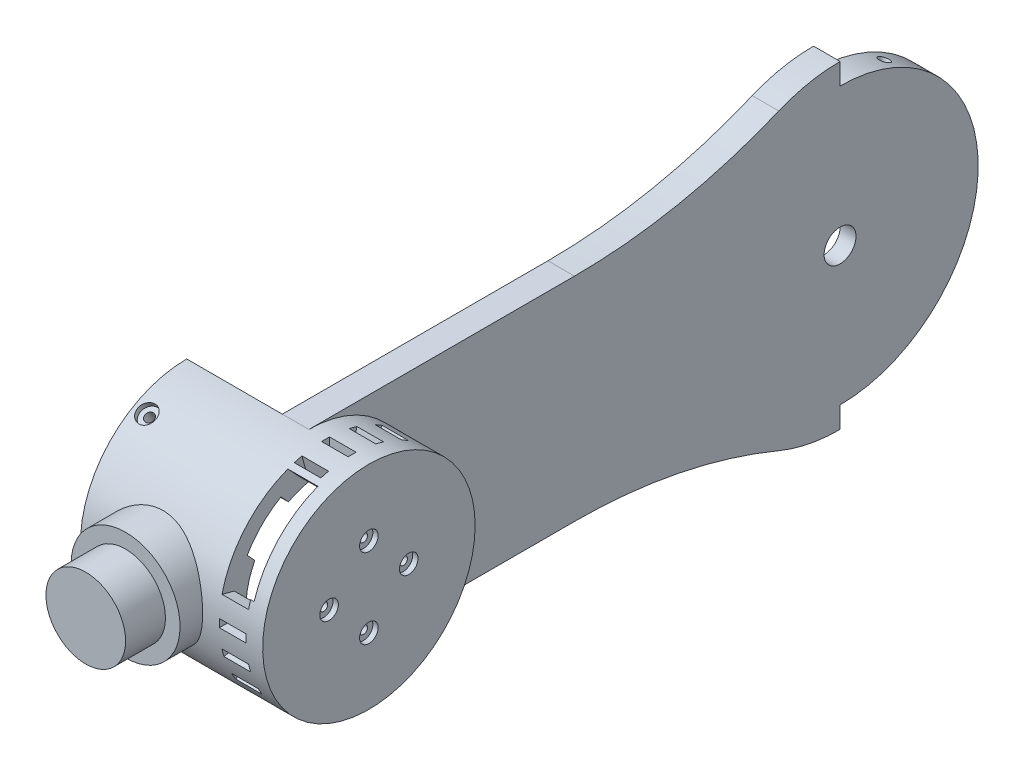
from build123d import *
from build123d.topology import SkipClean

# Parameters (mm, degrees)
SKETCH1_R                                            = 60
SKETCH1_R_2                                          = 45
SKETCH1_R_3                                          = 40
BOSS_EXTRUDE3_DEPTH                                  = 10
CUT_EXTRUDE1_DEPTH                                   = 248.588368063
CUT_EXTRUDE1_DEPTH_BACK                              = 248.588368063
SKETCH5_R                                            = 30
CUT_EXTRUDE2_DEPTH                                   = 248.588368063
CUT_EXTRUDE2_DEPTH_BACK                              = 248.588368063
SKETCH6_R                                            = 18.5
CUT_EXTRUDE3_DEPTH                                   = 4
SKETCH7_R                                            = 40
SKETCH7_R_2                                          = 30
BOSS_EXTRUDE4_DEPTH                                  = 17.6
SKETCH8_R                                            = 40
BOSS_EXTRUDE5_DEPTH                                  = 5
SKETCH9_R                                            = 1.5
CUT_EXTRUDE4_DEPTH                                   = 249.921192348
CUT_EXTRUDE4_DEPTH_BACK                              = 249.921192348
BOSS_EXTRUDE6_DEPTH                                  = 31
BOSS_EXTRUDE8_REACH                                  = 301.878
BOSS_EXTRUDE8_END_RADIUS                             = 40
SKETCH13_R                                           = 20.5
BOSS_EXTRUDE8_DIRECTION_2_DEPTH                      = 8.5
SKETCH16_R                                           = 15
BOSS_EXTRUDE9_DEPTH                                  = 15
SKETCH17_R                                           = 3.5
CUT_EXTRUDE5_DEPTH                                   = 2
BOSS_EXTRUDE11_DEPTH                                 = 5
CBORE_FOR_M3_HEXAGON_HEAD_BOLTS_FULL_THR_D           = 3.4
CBORE_FOR_M3_HEXAGON_HEAD_BOLTS_FULL_THR_CBORE_D     = 7
CBORE_FOR_M3_HEXAGON_HEAD_BOLTS_FULL_THR_CBORE_DEPTH = 2
CBORE_FOR_M3_HEXAGON_HEAD_BOLTS_FULL_2_D             = 3.4
CBORE_FOR_M3_HEXAGON_HEAD_BOLTS_FULL_2_CBORE_D       = 7
CBORE_FOR_M3_HEXAGON_HEAD_BOLTS_FULL_2_CBORE_DEPTH   = 2
SKETCH21_R                                           = 2.05
CUT_EXTRUDE6_DEPTH                                   = 13
SKETCH22_R                                           = 2.05
CUT_EXTRUDE7_DEPTH                                   = 13
F_4_0MM_DOWEL_HOLE1_D                                = 4.1
F_4_0MM_DOWEL_HOLE1_DEPTH                            = 7
F_4_0MM_DOWEL_HOLE1_TIP                              = 1.231764269
SKETCH24_R                                           = 6
CUT_EXTRUDE8_DEPTH                                   = 2.5
CUT_EXTRUDE9_REACH                                   = 310.539
CUT_EXTRUDE9_END_RADIUS                              = 30
SKETCH25_W                                           = 10
SKETCH25_H                                           = 3
CIRPATTERN1_COUNT                                    = 24
CUT_EXTRUDE10_REACH                                  = 301.691
CUT_EXTRUDE10_END_RADIUS                             = 30
SKETCH26_W                                           = 11.3
SKETCH26_H                                           = 35
CUT_EXTRUDE11_REACH                                  = 250.012
CUT_EXTRUDE11_END_RADIUS                             = 30
SKETCH27_W                                           = 32.246130699
SKETCH27_H                                           = 17.935567755
CUT_EXTRUDE11_DIRECTION_2_REACH                      = 250.012
CUT_EXTRUDE11_DIRECTION_2_END_RADIUS                 = 34
CUT_EXTRUDE12_REACH                                  = 275.189
SKETCH28_R                                           = 6


with BuildPart() as part:
    # Sketch1 → Boss-Extrude3 (new body)
    with BuildSketch(Plane(origin=(0, 0, 0), x_dir=(0, 0, -1), z_dir=(1, 0, 0))):
        Circle(SKETCH1_R)
        Circle(SKETCH1_R_2, mode=Mode.SUBTRACT)
        with BuildLine():
            ThreePointArc((-23.076923077, 55.384615385), (-60.776772972, 43.883864862), (-100, 40))
            Line((-100, 40), (-200, 40))
            ThreePointArc((-200, 40), (-171.715728753, 28.284271247), (-160, 0))
            ThreePointArc((-160, 0), (-171.715728753, -28.284271247), (-200, -40))
            Line((-200, -40), (-100, -40))
            ThreePointArc((-100, -40), (-60.776772972, -43.883864862), (-23.076923077, -55.384615385))
            ThreePointArc((-23.076923077, -55.384615385), (-60, 0), (-23.076923077, 55.384615385))
        make_face()
        with Locations((-200, 0)):
            Circle(SKETCH1_R_3)
        Circle(SKETCH1_R_2)
    extrude(amount=BOSS_EXTRUDE3_DEPTH)

    # Sketch4 → Cut-Extrude1 (cut, two sides)
    with BuildSketch(Plane(origin=(10, 0, 0), x_dir=(0, 0, -1), z_dir=(1, 0, 0))) as cut_extrude1_sk:
        with BuildLine():
            Line((0, 60), (0, 52))
            ThreePointArc((0, 52), (36.769552622, 36.769552622), (52, 0))
            ThreePointArc((52, 0), (36.769552622, -36.769552622), (0, -52))
            Line((0, -52), (0, -60))
            ThreePointArc((0, -60), (42.426406871, -42.426406871), (60, 0))
            ThreePointArc((60, 0), (42.426406871, 42.426406871), (0, 60))
        make_face()
    extrude(amount=CUT_EXTRUDE1_DEPTH, mode=Mode.SUBTRACT)
    extrude(cut_extrude1_sk.sketch, amount=-CUT_EXTRUDE1_DEPTH_BACK, mode=Mode.SUBTRACT)

    # Sketch5 → Cut-Extrude2 (cut, two sides)
    with BuildSketch(Plane(origin=(10, 0, 0), x_dir=(0, 0, -1), z_dir=(1, 0, 0))) as cut_extrude2_sk:
        with Locations((-200, 0)):
            Circle(SKETCH5_R)
    extrude(amount=CUT_EXTRUDE2_DEPTH, mode=Mode.SUBTRACT)
    extrude(cut_extrude2_sk.sketch, amount=-CUT_EXTRUDE2_DEPTH_BACK, mode=Mode.SUBTRACT)

    # Sketch6 → Cut-Extrude3 (cut)
    with BuildSketch(Plane.ZY):
        Circle(SKETCH6_R)
    extrude(amount=-CUT_EXTRUDE3_DEPTH, mode=Mode.SUBTRACT)

    # Sketch7 → Boss-Extrude4 (add)
    with BuildSketch(Plane(origin=(10, 0, 0), x_dir=(0, 0, -1), z_dir=(1, 0, 0))):
        with Locations(Location((-200, 0, 0), (0, 0, 270))):
            Circle(SKETCH7_R)
        with Locations((-200, 0)):
            Circle(SKETCH7_R_2, mode=Mode.SUBTRACT)
    extrude(amount=BOSS_EXTRUDE4_DEPTH)

    # Sketch8 → Boss-Extrude5 (add)
    with BuildSketch(Plane(origin=(27.6, 0, 0), x_dir=(0, 0, -1), z_dir=(1, 0, 0))):
        with Locations(Location((-200, 0, 0), (0, 0, 270))):
            Circle(SKETCH8_R)
    extrude(amount=BOSS_EXTRUDE5_DEPTH)

    # Sketch9 → Cut-Extrude4 (cut, two sides)
    with BuildSketch(Plane.ZY.offset(-27.6)) as cut_extrude4_sk:
        with Locations((200, 15)):
            Circle(SKETCH9_R)
        with Locations((215, 0)):
            Circle(SKETCH9_R)
        with Locations((200, -15)):
            Circle(SKETCH9_R)
        with Locations((185, 0)):
            Circle(SKETCH9_R)
    extrude(amount=CUT_EXTRUDE4_DEPTH, mode=Mode.SUBTRACT)
    extrude(cut_extrude4_sk.sketch, amount=-CUT_EXTRUDE4_DEPTH_BACK, mode=Mode.SUBTRACT)

    # Sketch10 → Boss-Extrude6 (add)
    with BuildSketch(Plane.ZY):
        with BuildLine():
            Line((200, 40), (200, 30))
            ThreePointArc((200, 30), (230, 0), (200, -30))
            Line((200, -30), (200, -40))
            ThreePointArc((200, -40), (240, 0), (200, 40))
        make_face()
    extrude(amount=BOSS_EXTRUDE6_DEPTH)

    # Boss-Extrude8: up to this cylinder (the profile starts outside it)
    boss_extrude8_end = Plane(origin=(-10.5, 0, 200), z_dir=(-1, 0, 0)) * Cylinder(BOSS_EXTRUDE8_END_RADIUS, 684.756, mode=Mode.PRIVATE)
    # Sketch13 → Boss-Extrude8 (add, up to the surface)
    with BuildSketch(Plane.XY.offset(240), mode=Mode.PRIVATE) as boss_extrude8_sk1:
        with Locations((-10.5, 0)):
            Circle(SKETCH13_R)
    boss_extrude8_tool1 = extrude(boss_extrude8_sk1.sketch, amount=-BOSS_EXTRUDE8_REACH, mode=Mode.PRIVATE) - boss_extrude8_end
    add(boss_extrude8_tool1.solids().sort_by_distance((-10.5, 0, 240))[0])
    add(boss_extrude8_tool1.solids().sort_by_distance((-10.5, 0, 240))[1])

    # Sketch13 → Boss-Extrude8 direction 2 (add)
    with BuildSketch(Plane.XY.offset(240)):
        with Locations((-10.5, 0)):
            Circle(SKETCH13_R)
    extrude(amount=BOSS_EXTRUDE8_DIRECTION_2_DEPTH)

    # Sketch16 → Boss-Extrude9 (add)
    with BuildSketch(Plane.XY.offset(248.5)):
        with Locations((-10.5, 0)):
            Circle(SKETCH16_R)
    extrude(amount=BOSS_EXTRUDE9_DEPTH)

    # Sketch17 → Cut-Extrude5 (cut)
    with BuildSketch(Plane(origin=(32.6, 0, 0), x_dir=(0, 0, -1), z_dir=(1, 0, 0))):
        with Locations((-200, -15)):
            Circle(SKETCH17_R)
        with Locations((-215, 0)):
            Circle(SKETCH17_R)
        with Locations((-200, 15)):
            Circle(SKETCH17_R)
        with Locations((-185, 0)):
            Circle(SKETCH17_R)
    extrude(amount=-CUT_EXTRUDE5_DEPTH, mode=Mode.SUBTRACT)

    # Sketch20 → Boss-Extrude11 (add)
    with BuildSketch(Plane.ZY.offset(31)):
        with BuildLine():
            Line((200, 40), (200, 30))
            ThreePointArc((200, 30), (230, 0), (200, -30))
            Line((200, -30), (200, -40))
            ThreePointArc((200, -40), (228.284271247, -28.284271247), (240, 0))
            ThreePointArc((240, 0), (228.284271247, 28.284271247), (200, 40))
        make_face()
    extrude(amount=BOSS_EXTRUDE11_DEPTH)

    # CBORE for M3 Hexagon head bolts-Full thr (through all)
    with Locations(Plane(origin=(-31, 34.641016151, 220), x_dir=(0, -0.5, 0.866025403784), z_dir=(0, 0.866025403784, 0.5))):
        with Locations((0, 0)):
            CounterBoreHole(CBORE_FOR_M3_HEXAGON_HEAD_BOLTS_FULL_THR_D / 2, CBORE_FOR_M3_HEXAGON_HEAD_BOLTS_FULL_THR_CBORE_D / 2, CBORE_FOR_M3_HEXAGON_HEAD_BOLTS_FULL_THR_CBORE_DEPTH)

    # CBORE for M3 Hexagon head bolts-Full 2 (through all)
    with Locations(Plane(origin=(-31, -34.641016151, 220), x_dir=(0, -0.500000174844, -0.866025302838), z_dir=(0, -0.866025302838, 0.500000174844))):
        with Locations((0, 0)):
            CounterBoreHole(CBORE_FOR_M3_HEXAGON_HEAD_BOLTS_FULL_2_D / 2, CBORE_FOR_M3_HEXAGON_HEAD_BOLTS_FULL_2_CBORE_D / 2, CBORE_FOR_M3_HEXAGON_HEAD_BOLTS_FULL_2_CBORE_DEPTH)

    # Sketch21 → Cut-Extrude6 (cut)
    with BuildSketch(Plane(origin=(0, 52.725441887, -24.166666667), x_dir=(1, 0, 0), z_dir=(0, 0.9090593428863094, -0.416666666666667))):
        with Locations(Location((5, 0, 0), (0, 0, 270))):
            Circle(SKETCH21_R)
    extrude(amount=-CUT_EXTRUDE6_DEPTH, mode=Mode.SUBTRACT)

    # Sketch22 → Cut-Extrude7 (cut)
    with BuildSketch(Plane(origin=(0, -52.725441887, -24.166666667), x_dir=(-1, 0, 0), z_dir=(0, -0.9090593428863094, -0.416666666666667))):
        with Locations(Location((-5, 0, 0), (0, 0, 90))):
            Circle(SKETCH22_R)
    extrude(amount=-CUT_EXTRUDE7_DEPTH, mode=Mode.SUBTRACT)

    # 4.0mm Dowel Hole1
    with Locations(Plane(origin=(-12, 35, 200), x_dir=(-1, 0, 0), z_dir=(0, 0, -1))):
        with Locations((0, 0), (0, -70)):
            Hole(F_4_0MM_DOWEL_HOLE1_D / 2, depth=F_4_0MM_DOWEL_HOLE1_DEPTH)
            with Locations((0, 0, -(F_4_0MM_DOWEL_HOLE1_DEPTH + F_4_0MM_DOWEL_HOLE1_TIP / 2))):  # 118° drill point
                Cone(0, F_4_0MM_DOWEL_HOLE1_D / 2, F_4_0MM_DOWEL_HOLE1_TIP, mode=Mode.SUBTRACT)

    # Sketch24 → Cut-Extrude8 (cut)
    with BuildSketch(Plane.ZY):
        with Locations((80, 25)):
            Circle(SKETCH24_R)
        with Locations((80, -25)):
            Circle(SKETCH24_R)
    extrude(amount=-CUT_EXTRUDE8_DEPTH, mode=Mode.SUBTRACT)

    # Cut-Extrude9: up to this cylinder (the profile starts outside it)
    with SkipClean():  # the faces are left unmerged after this step: merging them gives an invalid solid
        cut_extrude9_end = Plane(origin=(21.3, 0, 200), z_dir=(1, 0, 0)) * Cylinder(CUT_EXTRUDE9_END_RADIUS, 682.078, mode=Mode.PRIVATE)
        # Sketch25 → Cut-Extrude9 (cut, up to the surface)
        with BuildSketch(Plane.XY.offset(248.5), mode=Mode.PRIVATE) as cut_extrude9_sk1:
            with Locations((21.3, 0)):
                Rectangle(SKETCH25_W, SKETCH25_H)
        cut_extrude9_tool1 = extrude(cut_extrude9_sk1.sketch, amount=-CUT_EXTRUDE9_REACH, mode=Mode.PRIVATE) - cut_extrude9_end
        cut_extrude9 = cut_extrude9_tool1.solids().sort_by_distance((21.3, 0, 248.5))[0]
        add(cut_extrude9, mode=Mode.SUBTRACT)

    # CirPattern1: Cut-Extrude9 ×24 about axis
    with SkipClean():  # the faces are left unmerged after this step: merging them gives an invalid solid
        cirpattern1_axis = Axis((0, 0, 200), (1, 0, 0))
        for i in range(1, CIRPATTERN1_COUNT):
            add(cut_extrude9.rotate(cirpattern1_axis, i * 360 / CIRPATTERN1_COUNT), mode=Mode.SUBTRACT)

    # Cut-Extrude10: up to this cylinder (the profile starts outside it)
    with SkipClean():  # the faces are left unmerged after this step: merging them gives an invalid solid
        cut_extrude10_end = Plane(origin=(21.95, 0, 200), z_dir=(1, 0, 0)) * Cylinder(CUT_EXTRUDE10_END_RADIUS, 664.382, mode=Mode.PRIVATE)
        # Sketch26 → Cut-Extrude10 (cut, up to the surface)
        with BuildSketch(Plane(origin=(26.3, 29.325037044, 227.203716701), x_dir=(1, 0, 0), z_dir=(0, 0.7331259261111045, 0.6800929175221099)), mode=Mode.PRIVATE) as cut_extrude10_sk1:
            with Locations((-4.35, -2.5)):
                Rectangle(SKETCH26_W, SKETCH26_H)
        cut_extrude10_tool1 = extrude(cut_extrude10_sk1.sketch, amount=-CUT_EXTRUDE10_REACH, mode=Mode.PRIVATE) - cut_extrude10_end
        add(cut_extrude10_tool1.solids().sort_by_distance((21.95, 27.624805, 229.036532))[0], mode=Mode.SUBTRACT)

    # Cut-Extrude11: up to this cylinder (the profile starts outside it)
    with SkipClean():  # the faces are left unmerged after this step: merging them gives an invalid solid
        cut_extrude11_end = Plane(origin=(0.176935, 0, 200), z_dir=(1, 0, 0)) * Cylinder(CUT_EXTRUDE11_END_RADIUS, 561.024, mode=Mode.PRIVATE)
        # Sketch27 → Cut-Extrude11 (cut, up to the surface)
        with BuildSketch(Plane(origin=(0, 121.712527783, 112.908062818), x_dir=(-1, 0, 0), z_dir=(0, -0.7331259261111045, -0.6800929175221099)), mode=Mode.PRIVATE) as cut_extrude11_sk1:
            with Locations((-0.17693465, -147.807670358)):
                Rectangle(SKETCH27_W, SKETCH27_H)
        cut_extrude11_tool1 = extrude(cut_extrude11_sk1.sketch, amount=CUT_EXTRUDE11_REACH, mode=Mode.PRIVATE) - cut_extrude11_end
        add(cut_extrude11_tool1.solids().sort_by_distance((0.176935, 21.189578, 221.269698))[0], mode=Mode.SUBTRACT)
        add(cut_extrude11_tool1.solids().sort_by_distance((0.176935, 21.189578, 221.269698))[1], mode=Mode.SUBTRACT)

    # Cut-Extrude11 direction 2: up to this cylinder (the profile starts inside it)
    with SkipClean():  # the faces are left unmerged after this step: merging them gives an invalid solid
        cut_extrude11_direction_2_end = Plane(origin=(0.176935, 0, 200), z_dir=(-1, 0, 0)) * Cylinder(CUT_EXTRUDE11_DIRECTION_2_END_RADIUS, 569.024, mode=Mode.PRIVATE)
        # Sketch27 → Cut-Extrude11 direction 2 (cut, up to the surface)
        with BuildSketch(Plane(origin=(0, 121.712527783, 112.908062818), x_dir=(-1, 0, 0), z_dir=(0, -0.7331259261111045, -0.6800929175221099)), mode=Mode.PRIVATE) as cut_extrude11_direction_2_sk1:
            with Locations((-0.17693465, -147.807670358)):
                Rectangle(SKETCH27_W, SKETCH27_H)
        cut_extrude11_direction_2_tool1 = extrude(cut_extrude11_direction_2_sk1.sketch, amount=-CUT_EXTRUDE11_DIRECTION_2_REACH, mode=Mode.PRIVATE) & cut_extrude11_direction_2_end
        add(cut_extrude11_direction_2_tool1.solids().sort_by_distance((0.176935, 21.189578, 221.269698))[0], mode=Mode.SUBTRACT)

    # Sketch28 → Cut-Extrude12 (cut, up to next)
    with BuildSketch(Plane.ZY.offset(-4), mode=Mode.PRIVATE) as cut_extrude12_sk1:
        Circle(SKETCH28_R)
    cut_extrude12_tool1 = extrude(cut_extrude12_sk1.sketch, amount=-CUT_EXTRUDE12_REACH, mode=Mode.PRIVATE) & part.part
    add(cut_extrude12_tool1.solids().sort_by_distance((4, 0, 0))[0], mode=Mode.SUBTRACT)


solid = part.part
